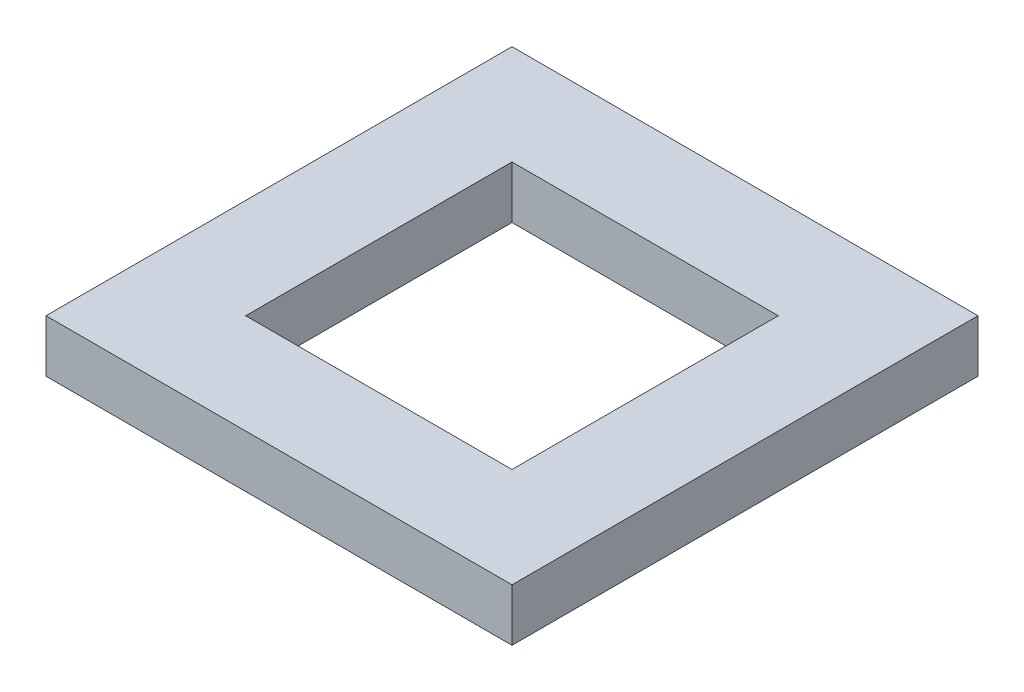
from build123d import *

# Parameters (mm, degrees)
SKETCH1_W           = 88.9
SKETCH1_H           = 88.9
BOSS_EXTRUDE1_DEPTH = 10
CUT_EXTRUDE1_REACH  = 12
SKETCH2_W           = 50.8
SKETCH2_H           = 50.8


with BuildPart() as part:
    # Sketch1 → Boss-Extrude1 (new body)
    with BuildSketch(Plane(origin=(0, 0, 0), x_dir=(1, 0, 0), z_dir=(0, 1, 0))):
        Rectangle(SKETCH1_W, SKETCH1_H)
    extrude(amount=BOSS_EXTRUDE1_DEPTH)

    # Sketch2 → Cut-Extrude1 (cut, up to next)
    with BuildSketch(Plane(origin=(0, 10, 0), x_dir=(1, 0, 0), z_dir=(0, 1, 0)), mode=Mode.PRIVATE) as cut_extrude1_sk1:
        Rectangle(SKETCH2_W, SKETCH2_H)
    cut_extrude1_tool1 = extrude(cut_extrude1_sk1.sketch, amount=-CUT_EXTRUDE1_REACH, mode=Mode.PRIVATE) & part.part
    add(cut_extrude1_tool1.solids().sort_by_distance((0, 10, 0))[0], mode=Mode.SUBTRACT)


solid = part.part
